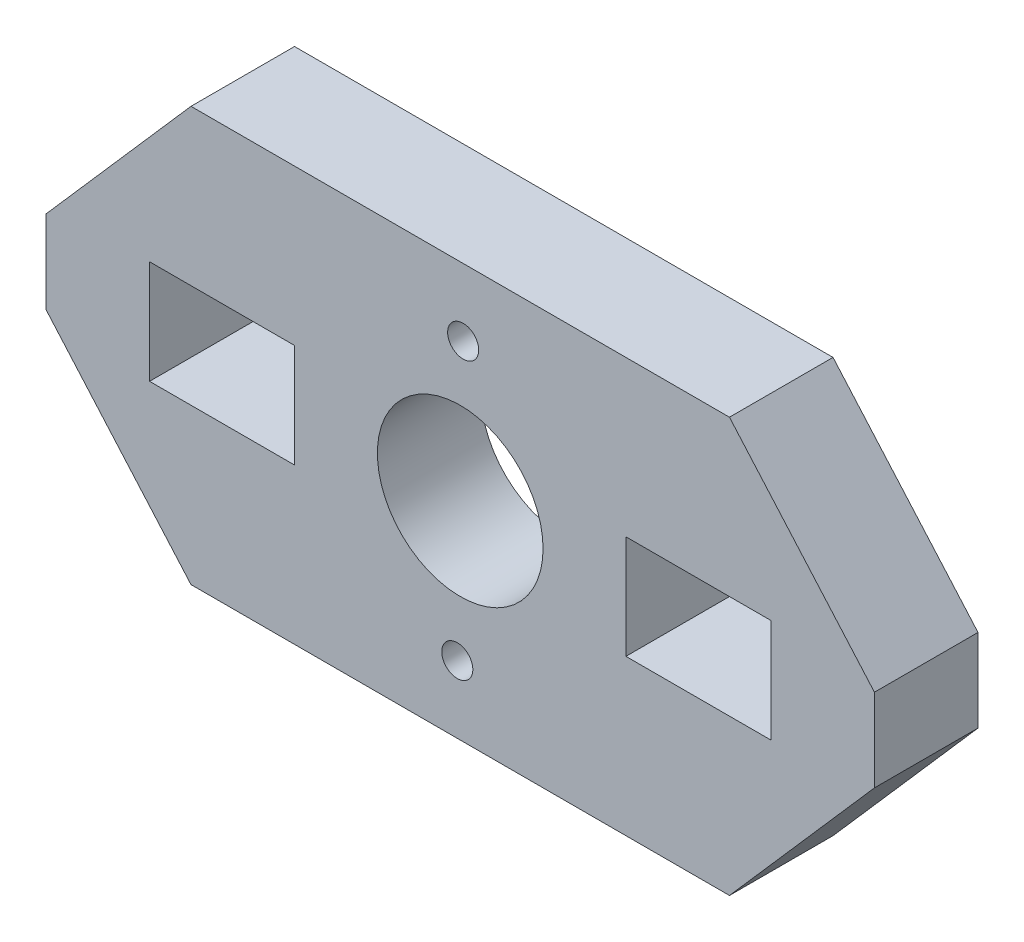
from build123d import *

# Parameters (mm, degrees)
SKETCH1_R               = 4
SKETCH1_R_2             = 0.75
BOSS_EXTRUDE1_DEPTH     = 5
CUT_EXTRUDE1_DEPTH      = 5
CUT_EXTRUDE1_DEPTH_BACK = 5
SKETCH2_W               = 7
SKETCH2_H               = 5


with BuildPart() as part:
    # Sketch1 → Boss-Extrude1 (new body)
    with BuildSketch(Plane.XY):
        Polygon((-30.771428571, -18.807142857), (-4.771428571, -18.807142857), (2.228571429, -10.807142857), (2.228571429, -6.807142857), (-4.771428571, 1.192857143), (-30.771428571, 1.192857143), (-37.771428571, -6.807142857), (-37.771428571, -10.807142857), align=None)
        with Locations((-17.771428571, -8.807142857)):
            Circle(SKETCH1_R, mode=Mode.SUBTRACT)
        with Locations((-17.629745485, -2.058630135)):
            Circle(SKETCH1_R_2, mode=Mode.SUBTRACT)
        with Locations((-17.913111664, -15.555655867)):
            Circle(SKETCH1_R_2, mode=Mode.SUBTRACT)
    extrude(amount=BOSS_EXTRUDE1_DEPTH)

    # Sketch2 → Cut-Extrude1 (cut, two sides: drawn at the far end of the back side and taken through both)
    with BuildSketch(Plane.XY.offset(5).offset(-CUT_EXTRUDE1_DEPTH_BACK)):
        with Locations((-29.271428571, -8.807142857)):
            Rectangle(SKETCH2_W, SKETCH2_H)
        with Locations((-6.271428571, -8.807142857)):
            Rectangle(SKETCH2_W, SKETCH2_H)
    extrude(amount=CUT_EXTRUDE1_DEPTH + CUT_EXTRUDE1_DEPTH_BACK, mode=Mode.SUBTRACT)


solid = part.part
